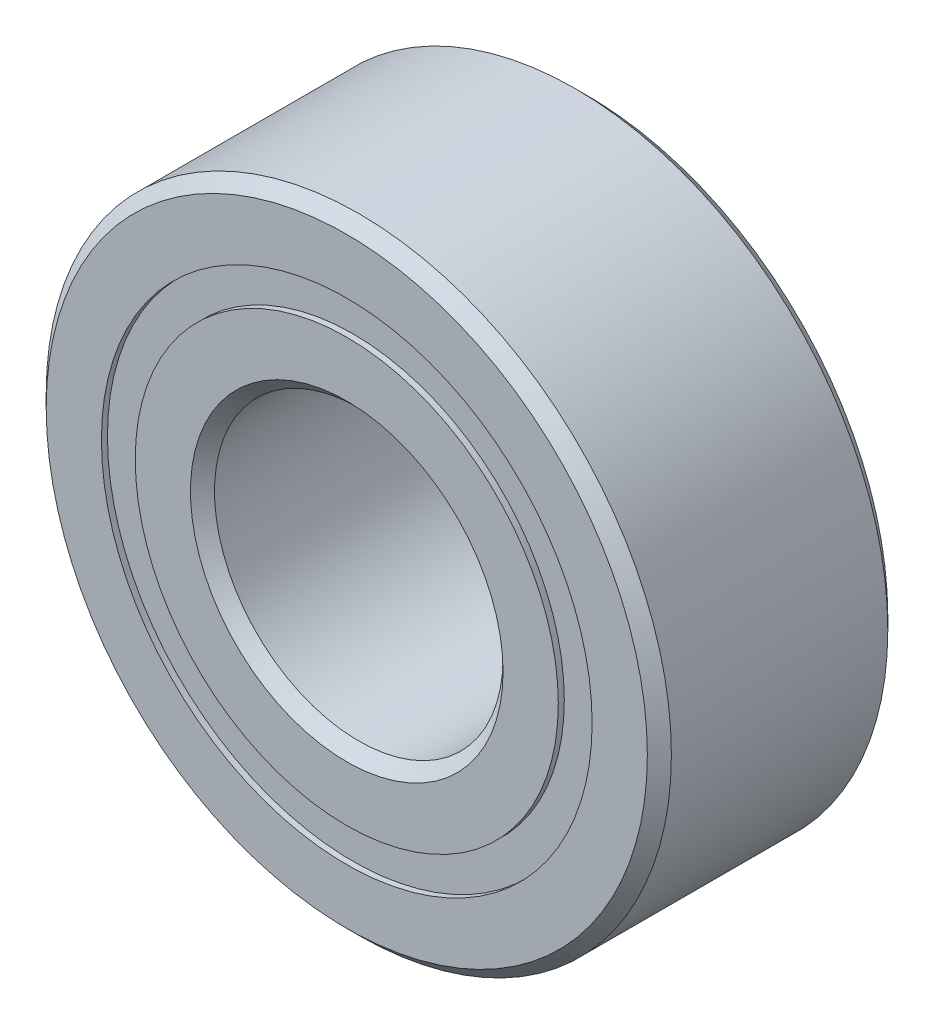
from build123d import *

# Parameters (mm, degrees)
CIRPATTERN1_COUNT = 12
SKETCH5_W         = 1.209571124
SKETCH5_H         = 0.703296704


with BuildPart() as part:
    # Sketch1 → Revolve1 (revolve)
    with BuildSketch(Plane(origin=(0, 0, 0), x_dir=(0, 0, -1), z_dir=(1, 0, 0))):
        with BuildLine():
            Line((2.25, 6.5), (-2.25, 6.5))
            Line((-2.25, 6.5), (-2.5, 6.25))
            Line((-2.5, 6.25), (-2.5, 5.101648352))
            Line((-2.5, 5.101648352), (-1.111111111, 5.101648352))
            ThreePointArc((-1.111111111, 5.101648352), (0, 5.915428876), (1.111111111, 5.101648352))
            Line((1.111111111, 5.101648352), (2.5, 5.101648352))
            Line((2.5, 5.101648352), (2.5, 6.25))
            Line((2.5, 6.25), (2.25, 6.5))
        make_face()
    revolve(axis=Axis((0, 0, 2.5), (0, 0, -1)))


with BuildPart() as body_2:
    # Sketch3 → Revolve3 (revolve)
    with BuildSketch(Plane(origin=(0, 0, 0), x_dir=(0, 0, -1), z_dir=(1, 0, 0))):
        with BuildLine():
            Line((-2.5, 4.398351648), (-1.111111111, 4.398351648))
            ThreePointArc((-1.111111111, 4.398351648), (0, 3.584571124), (1.111111111, 4.398351648))
            Line((1.111111111, 4.398351648), (2.5, 4.398351648))
            Line((2.5, 4.398351648), (2.5, 3.25))
            Line((2.5, 3.25), (2.25, 3))
            Line((2.25, 3), (-2.25, 3))
            Line((-2.25, 3), (-2.5, 3.25))
            Line((-2.5, 3.25), (-2.5, 4.398351648))
        make_face()
    revolve(axis=Axis((0, 0, 2.5), (0, 0, -1)))


with BuildPart() as body_3:
    # Sketch4 → Revolve4 (revolve)
    with BuildSketch(Plane(origin=(0, 0, 0), x_dir=(0, 0, -1), z_dir=(1, 0, 0))):
        with BuildLine():
            Line((-1.165428876, 4.75), (1.165428876, 4.75))
            ThreePointArc((1.165428876, 4.75), (0, 5.915428876), (-1.165428876, 4.75))
        make_face()
    revolve(axis=Axis((0, 4.75, 1.165428876), (0, 0, -1)))


with BuildPart() as cirpattern1_1:
    # CirPattern1: pattern copy
    add(body_3.part.rotate(Axis((0, 0, -2.5), (0, 0, 1)), 1 * 360 / CIRPATTERN1_COUNT))


with BuildPart() as cirpattern1_2:
    # CirPattern1: pattern copy
    add(body_3.part.rotate(Axis((0, 0, -2.5), (0, 0, 1)), 2 * 360 / CIRPATTERN1_COUNT))


with BuildPart() as cirpattern1_3:
    # CirPattern1: pattern copy
    add(body_3.part.rotate(Axis((0, 0, -2.5), (0, 0, 1)), 3 * 360 / CIRPATTERN1_COUNT))


with BuildPart() as cirpattern1_4:
    # CirPattern1: pattern copy
    add(body_3.part.rotate(Axis((0, 0, -2.5), (0, 0, 1)), 4 * 360 / CIRPATTERN1_COUNT))


with BuildPart() as cirpattern1_5:
    # CirPattern1: pattern copy
    add(body_3.part.rotate(Axis((0, 0, -2.5), (0, 0, 1)), 5 * 360 / CIRPATTERN1_COUNT))


with BuildPart() as cirpattern1_6:
    # CirPattern1: pattern copy
    add(body_3.part.rotate(Axis((0, 0, -2.5), (0, 0, 1)), 6 * 360 / CIRPATTERN1_COUNT))


with BuildPart() as cirpattern1_7:
    # CirPattern1: pattern copy
    add(body_3.part.rotate(Axis((0, 0, -2.5), (0, 0, 1)), 7 * 360 / CIRPATTERN1_COUNT))


with BuildPart() as cirpattern1_8:
    # CirPattern1: pattern copy
    add(body_3.part.rotate(Axis((0, 0, -2.5), (0, 0, 1)), 8 * 360 / CIRPATTERN1_COUNT))


with BuildPart() as cirpattern1_9:
    # CirPattern1: pattern copy
    add(body_3.part.rotate(Axis((0, 0, -2.5), (0, 0, 1)), 9 * 360 / CIRPATTERN1_COUNT))


with BuildPart() as cirpattern1_10:
    # CirPattern1: pattern copy
    add(body_3.part.rotate(Axis((0, 0, -2.5), (0, 0, 1)), 10 * 360 / CIRPATTERN1_COUNT))


with BuildPart() as cirpattern1_11:
    # CirPattern1: pattern copy
    add(body_3.part.rotate(Axis((0, 0, -2.5), (0, 0, 1)), 11 * 360 / CIRPATTERN1_COUNT))


with BuildPart() as body_15:
    # Sketch5 → Revolve5 (revolve)
    with BuildSketch(Plane(origin=(0, 0, 0), x_dir=(0, 0, -1), z_dir=(1, 0, 0))):
        with Locations((-1.770214438, 4.75)):
            Rectangle(SKETCH5_W, SKETCH5_H)
        with Locations((1.770214438, 4.75)):
            Rectangle(SKETCH5_W, SKETCH5_H)
    revolve(axis=Axis((0, 0, 2.5), (0, 0, -1)))


solid = Compound([part.part, body_2.part, body_3.part, cirpattern1_1.part, cirpattern1_2.part, cirpattern1_3.part, cirpattern1_4.part, cirpattern1_5.part, cirpattern1_6.part, cirpattern1_7.part, cirpattern1_8.part, cirpattern1_9.part, cirpattern1_10.part, cirpattern1_11.part, body_15.part])
